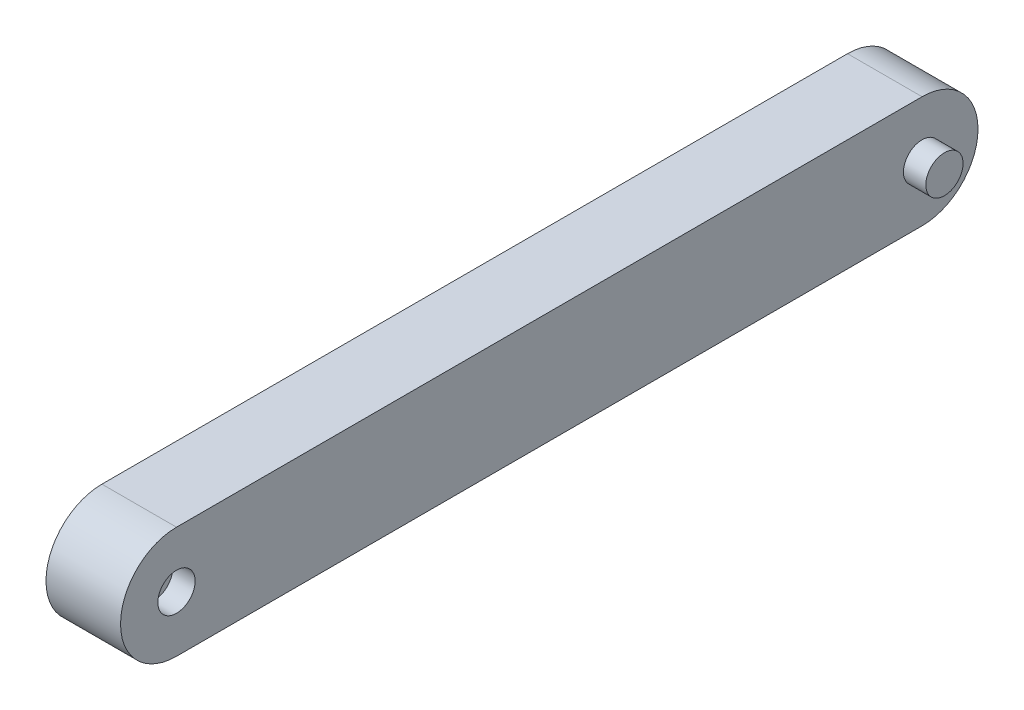
from build123d import *

# Parameters (mm, degrees)
BOSS_EXTRUDE2_DEPTH = 20
SKETCH4_R           = 5
BOSS_EXTRUDE3_DEPTH = 6
SKETCH5_R           = 5
CUT_EXTRUDE1_DEPTH  = 6


with BuildPart() as part:
    # Sketch3 → Boss-Extrude2 (new body)
    with BuildSketch(Plane(origin=(0, 0, 0), x_dir=(0, 0, -1), z_dir=(1, 0, 0))):
        with BuildLine():
            Line((100, -15), (-100, -15))
            ThreePointArc((-100, -15), (-115, 0), (-100, 15))
            Line((-100, 15), (100.0000001, 15))
            ThreePointArc((100.0000001, 15), (115.00000005, -5e-08), (100, -15))
        make_face()
    extrude(amount=BOSS_EXTRUDE2_DEPTH)

    # Sketch4 → Boss-Extrude3 (add)
    with BuildSketch(Plane(origin=(20, 0, 0), x_dir=(0, 0, -1), z_dir=(1, 0, 0))):
        with Locations((100.00000005, 0)):
            Circle(SKETCH4_R)
    boss_extrude3 = extrude(amount=BOSS_EXTRUDE3_DEPTH)

    # Sketch5 → Cut-Extrude1 (cut)
    with BuildSketch(Plane(origin=(20, 0, 0), x_dir=(0, 0, -1), z_dir=(1, 0, 0))):
        with Locations((-100, 0)):
            Circle(SKETCH5_R)
    cut_extrude1 = extrude(amount=-CUT_EXTRUDE1_DEPTH, mode=Mode.SUBTRACT)

    # Mirror1: Boss-Extrude3, Cut-Extrude1 across plane
    add(boss_extrude3.mirror(Plane(origin=(10, 0, 0), x_dir=(0, 0, 1), z_dir=(1, 0, 0))))
    add(cut_extrude1.mirror(Plane(origin=(10, 0, 0), x_dir=(0, 0, 1), z_dir=(1, 0, 0))), mode=Mode.SUBTRACT)


solid = part.part
